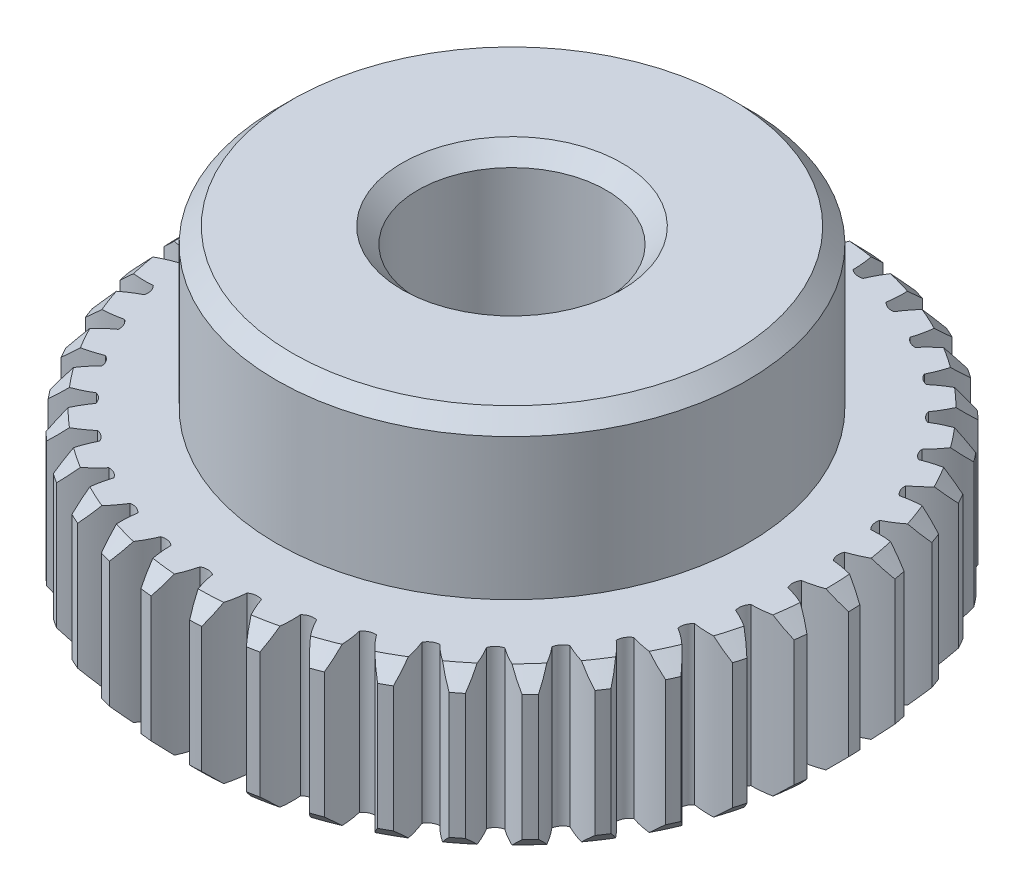
from build123d import *

# Parameters (mm, degrees)
SKETCH_1_R               = 21
EXTRUDE_1_DEPTH          = 10
CUT_EXTRUDE_1_DEPTH      = 10
CHAMFER_1_SIZE           = 1
PATTERN_CIRCULAR_1_COUNT = 40
SKETCH_4_R               = 15
EXTRUDE_2_DEPTH          = 10
SKETCH_3_R               = 6
CUT_EXTRUDE_2_DEPTH      = 21
CHAMFER_3_SIZE           = 1
CHAMFER_2_SIZE           = 1


with BuildPart() as part:
    # 草圖1 → 填料-伸長1 (new body)
    with BuildSketch(Plane(origin=(0, 0, 0), x_dir=(1, 0, 0), z_dir=(0, 1, 0))):
        Circle(SKETCH_1_R)
    extrude(amount=EXTRUDE_1_DEPTH)

    # 草圖2 → 除料-伸長1 (cut)
    with BuildSketch(Plane(origin=(0, 10, 0), x_dir=(1, 0, 0), z_dir=(0, 1, 0))):
        with BuildLine():
            ThreePointArc((0.324223669, 18.756008274), (0.032198175, 19.909566878), (-0.45531984, 20.995063321))
            ThreePointArc((-0.45531984, 20.995063321), (0.824456131, 20.983809761), (2.101169924, 20.894618564))
            ThreePointArc((2.101169924, 20.894618564), (1.529987695, 19.850718567), (1.148355253, 18.723628056))
            ThreePointArc((1.148355253, 18.723628056), (0.732041775, 18.631707334), (0.324223669, 18.756008274))
        make_face()
    cut_extrude_1 = extrude(amount=-CUT_EXTRUDE_1_DEPTH, mode=Mode.SUBTRACT)

    # 導角1
    chamfer_1_edges = [part.edges().sort_by_distance(p)[0] for p in [
        (-14.687380354, 0, 15.009359024),
        (-14.687380354, 10, 15.009359024),
    ]]
    chamfer(chamfer_1_edges, length=CHAMFER_1_SIZE)

    # 環狀複製排列1: 除料-伸長1 ×40 about axis
    pattern_circular_1_axis = Axis((0, 0, 0), (0, 1, 0))
    for i in range(1, PATTERN_CIRCULAR_1_COUNT):
        add(cut_extrude_1.rotate(pattern_circular_1_axis, i * 360 / PATTERN_CIRCULAR_1_COUNT), mode=Mode.SUBTRACT)

    # 草圖4 → 填料-伸長2 (add)
    with BuildSketch(Plane(origin=(0, 10, 0), x_dir=(1, 0, 0), z_dir=(0, 1, 0))):
        Circle(SKETCH_4_R)
    extrude(amount=EXTRUDE_2_DEPTH)

    # 草圖3 → 除料-伸長2 (cut, through all)
    with BuildSketch(Plane.XZ):
        Circle(SKETCH_3_R)
    extrude(amount=-CUT_EXTRUDE_2_DEPTH, mode=Mode.SUBTRACT)

    # 導角3
    chamfer_3_edges = [part.edges().sort_by_distance(p)[0] for p in [
        (-15, 20, 0),
    ]]
    chamfer(chamfer_3_edges, length=CHAMFER_3_SIZE)

    # 導角2
    chamfer_2_edges = [part.edges().sort_by_distance(p)[0] for p in [
        (-6, 20, 0),
        (-6, 0, 0),
    ]]
    chamfer(chamfer_2_edges, length=CHAMFER_2_SIZE)


solid = part.part
